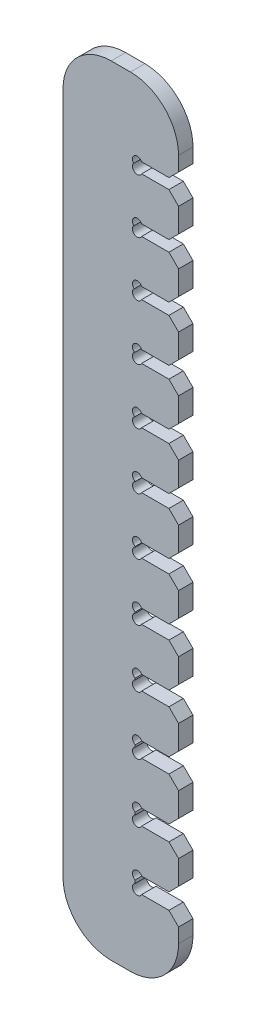
from build123d import *

# Parameters (mm, degrees)
BOSS_EXTRUDE1_DEPTH   = 1.5
CHAMFER1_SIZE         = 1
F_1_0MM_DOWEL_HOLE1_D = 1


with BuildPart() as part:
    # Sketch1 → Boss-Extrude1 (new body)
    with BuildSketch(Plane.XY):
        with BuildLine():
            Line((0, 35.4625), (0, -35.4625))
            ThreePointArc((0, -35.4625), (1.464466094, -38.998033906), (5, -40.4625))
            Line((5, -40.4625), (7, -40.4625))
            ThreePointArc((7, -40.4625), (10.535533906, -38.998033906), (12, -35.4625))
            Line((12, -35.4625), (12, -32.9625))
            Line((12, -32.9625), (7.5, -32.9625))
            Line((7.5, -32.9625), (7.5, -31.305))
            Line((7.5, -31.305), (12, -31.305))
            Line((12, -31.305), (12, -26.805))
            Line((12, -26.805), (7.5, -26.805))
            Line((7.5, -26.805), (7.5, -25.2))
            Line((7.5, -25.2), (12, -25.2))
            Line((12, -25.2), (12, -20.7))
            Line((12, -20.7), (7.5, -20.7))
            Line((7.5, -20.7), (7.5, -19.1475))
            Line((7.5, -19.1475), (12, -19.1475))
            Line((12, -19.1475), (12, -14.6475))
            Line((12, -14.6475), (7.5, -14.6475))
            Line((7.5, -14.6475), (7.5, -13.1475))
            Line((7.5, -13.1475), (12, -13.1475))
            Line((12, -13.1475), (12, -8.6475))
            Line((12, -8.6475), (7.5, -8.6475))
            Line((7.5, -8.6475), (7.5, -7.2))
            Line((7.5, -7.2), (12, -7.2))
            Line((12, -7.2), (12, -2.7))
            Line((12, -2.7), (7.5, -2.7))
            Line((7.5, -2.7), (7.5, -1.305))
            Line((7.5, -1.305), (12, -1.305))
            Line((12, -1.305), (12, 3.195))
            Line((12, 3.195), (7.5, 3.195))
            Line((7.5, 3.195), (7.5, 4.5375))
            Line((7.5, 4.5375), (12, 4.5375))
            Line((12, 4.5375), (12, 9.0375))
            Line((12, 9.0375), (7.5, 9.0375))
            Line((7.5, 9.0375), (7.5, 10.3275))
            Line((7.5, 10.3275), (12, 10.3275))
            Line((12, 10.3275), (12, 14.8275))
            Line((12, 14.8275), (7.5, 14.8275))
            Line((7.5, 14.8275), (7.5, 16.065))
            Line((7.5, 16.065), (12, 16.065))
            Line((12, 16.065), (12, 20.565))
            Line((12, 20.565), (7.5, 20.565))
            Line((7.5, 20.565), (7.5, 21.75))
            Line((7.5, 21.75), (12, 21.75))
            Line((12, 21.75), (12, 26.25))
            Line((12, 26.25), (7.5, 26.25))
            Line((7.5, 26.25), (7.5, 27.3825))
            Line((7.5, 27.3825), (12, 27.3825))
            Line((12, 27.3825), (12, 31.8825))
            Line((12, 31.8825), (7.5, 31.8825))
            Line((7.5, 31.8825), (7.5, 32.9625))
            Line((7.5, 32.9625), (12, 32.9625))
            Line((12, 32.9625), (12, 35.4625))
            ThreePointArc((12, 35.4625), (10.535533906, 38.998033906), (7, 40.4625))
            Line((7, 40.4625), (5, 40.4625))
            ThreePointArc((5, 40.4625), (1.464466094, 38.998033906), (0, 35.4625))
        make_face()
    extrude(amount=BOSS_EXTRUDE1_DEPTH)

    # Chamfer1
    chamfer1_edges = [part.edges().sort_by_distance(p)[0] for p in [
        (12, 31.8825, 0.75),
        (12, 27.3825, 0.75),
        (12, 26.25, 0.75),
        (12, 21.75, 0.75),
        (12, 20.565, 0.75),
        (12, 16.065, 0.75),
        (12, 14.8275, 0.75),
        (12, 10.3275, 0.75),
        (12, 9.0375, 0.75),
        (12, 4.5375, 0.75),
        (12, 3.195, 0.75),
        (12, -1.305, 0.75),
        (12, -2.7, 0.75),
        (12, -7.2, 0.75),
        (12, -8.6475, 0.75),
        (12, -13.1475, 0.75),
        (12, -14.6475, 0.75),
        (12, -19.1475, 0.75),
        (12, -20.7, 0.75),
        (12, -25.2, 0.75),
        (12, -26.805, 0.75),
        (12, -31.305, 0.75),
        (12, -32.9625, 0.75),
        (12, 32.9625, 0.75),
    ]]
    chamfer(chamfer1_edges, length=CHAMFER1_SIZE)

    # Ø1.0mm Dowel Hole1 (through all)
    with Locations(Plane.XY.offset(1.5)):
        with Locations((7.712132034, 32.750367966), (7.712132034, 32.094632034), (7.712132034, 27.170367966), (7.712132034, 26.462132034), (7.712132034, 21.537867966), (7.712132034, 20.777132034), (7.712132034, 15.852867966), (7.712132034, 15.039632034), (7.712132034, 10.115367966), (7.712132034, 9.249632034), (7.712132034, 4.325367966), (7.712132034, 3.407132034), (7.712132034, -1.517132034), (7.712132034, -2.487867966), (7.712132034, -7.412132034), (7.712132034, -8.435367966), (7.712132034, -13.359632034), (7.712132034, -14.435367966), (7.712132034, -19.359632034), (7.712132034, -20.487867966), (7.712132034, -25.412132034), (7.712132034, -26.592867966), (7.712132034, -31.517132034), (7.712132034, -32.750367966)):
            Hole(F_1_0MM_DOWEL_HOLE1_D / 2)


solid = part.part
